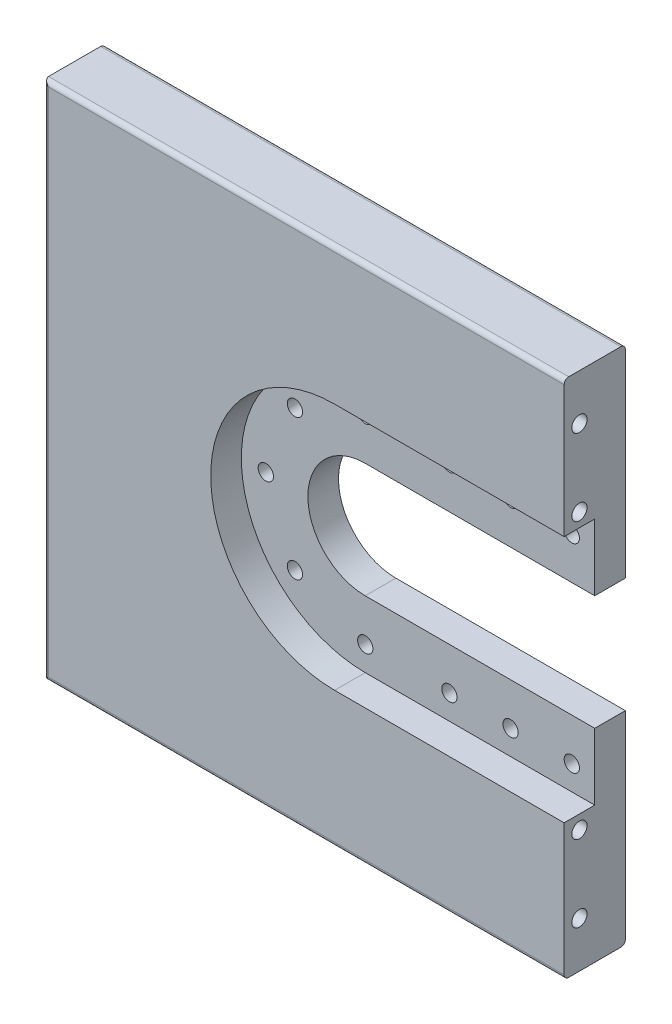
from build123d import *

# Parameters (mm, degrees)
SKETCH2_W               = 340
SKETCH2_H               = 340
BOSS_EXTRUDE1_DEPTH     = 40
CUT_EXTRUDE1_DEPTH      = 20
CUT_EXTRUDE2_DEPTH      = 100
CUT_EXTRUDE2_DEPTH_BACK = 199
SKETCH5_R               = 5
CUT_EXTRUDE4_DEPTH      = 363
CUT_EXTRUDE4_DEPTH_BACK = 260
SKETCH6_R               = 5
CUT_EXTRUDE5_DEPTH      = 18
FILLET1_R               = 3


with BuildPart() as part:
    # Sketch2 → Boss-Extrude1 (new body)
    with BuildSketch(Plane.XY):
        with Locations((0, 170)):
            Rectangle(SKETCH2_W, SKETCH2_H)
    extrude(amount=-BOSS_EXTRUDE1_DEPTH)

    # Sketch3 → Cut-Extrude1 (cut)
    with BuildSketch(Plane.XY):
        with BuildLine():
            ThreePointArc((20, 207.5), (-17.5, 170), (20, 132.5))
            Line((20, 132.5), (170, 132.5))
            Line((170, 132.5), (170, 89))
            Line((170, 89), (20, 89))
            ThreePointArc((20, 89), (-61, 170), (20, 251))
            Line((20, 251), (170, 251))
            Line((170, 251), (170, 207.5))
            Line((170, 207.5), (20, 207.5))
        make_face()
    extrude(amount=-CUT_EXTRUDE1_DEPTH, mode=Mode.SUBTRACT)

    # Sketch4 → Cut-Extrude2 (cut, two sides)
    with BuildSketch(Plane.XY) as cut_extrude2_sk:
        with BuildLine():
            Line((170, 132.5), (170, 207.5))
            Line((170, 207.5), (20, 207.5))
            ThreePointArc((20, 207.5), (-17.5, 170), (20, 132.5))
            Line((20, 132.5), (170, 132.5))
        make_face()
    extrude(amount=CUT_EXTRUDE2_DEPTH, mode=Mode.SUBTRACT)
    extrude(cut_extrude2_sk.sketch, amount=-CUT_EXTRUDE2_DEPTH_BACK, mode=Mode.SUBTRACT)

    # Sketch5 → Cut-Extrude4 (cut, two sides)
    with BuildSketch(Plane.XY) as cut_extrude4_sk:
        with Locations(Location((20, 235, 0), (0, 0, 180))):
            Circle(SKETCH5_R)
        with Locations(Location((20, 105, 0), (0, 0, 180))):
            Circle(SKETCH5_R)
        with Locations(Location((75, 235, 0), (0, 0, 180))):
            Circle(SKETCH5_R)
        with Locations(Location((75, 105, 0), (0, 0, 180))):
            Circle(SKETCH5_R)
        with Locations(Location((115, 235, 0), (0, 0, 180))):
            Circle(SKETCH5_R)
        with Locations(Location((155, 235, 0), (0, 0, 180))):
            Circle(SKETCH5_R)
        with Locations(Location((115, 105, 0), (0, 0, 180))):
            Circle(SKETCH5_R)
        with Locations(Location((155, 105, 0), (0, 0, 180))):
            Circle(SKETCH5_R)
        with Locations(Location((-25.961940777, 215.961940777, 0), (0, 0, 180))):
            Circle(SKETCH5_R)
        with Locations(Location((-45, 170, 0), (0, 0, 180))):
            Circle(SKETCH5_R)
        with Locations(Location((-25.961940777, 124.038059223, 0), (0, 0, 180))):
            Circle(SKETCH5_R)
    extrude(amount=CUT_EXTRUDE4_DEPTH, mode=Mode.SUBTRACT)
    extrude(cut_extrude4_sk.sketch, amount=-CUT_EXTRUDE4_DEPTH_BACK, mode=Mode.SUBTRACT)

    # Sketch6 → Cut-Extrude5 (cut)
    with BuildSketch(Plane(origin=(170, 0, 0), x_dir=(0, 0, -1), z_dir=(1, 0, 0))):
        with Locations(Location((10, 80, 0), (0, 0, 90))):
            Circle(SKETCH6_R)
        with Locations(Location((10, 310, 0), (0, 0, 90))):
            Circle(SKETCH6_R)
        with Locations(Location((10, 260, 0), (0, 0, 90))):
            Circle(SKETCH6_R)
        with Locations(Location((10, 30, 0), (0, 0, 90))):
            Circle(SKETCH6_R)
    extrude(amount=-CUT_EXTRUDE5_DEPTH, mode=Mode.SUBTRACT)

    # Fillet1
    fillet1_edges = [part.edges().sort_by_distance(p)[0] for p in [
        (0, 340, -40),
        (-170, 170, -40),
        (0, 340, 0),
        (0, 0, 0),
        (-170, 170, 0),
        (0, 0, -40),
    ]]
    fillet(fillet1_edges, radius=FILLET1_R)


solid = part.part
